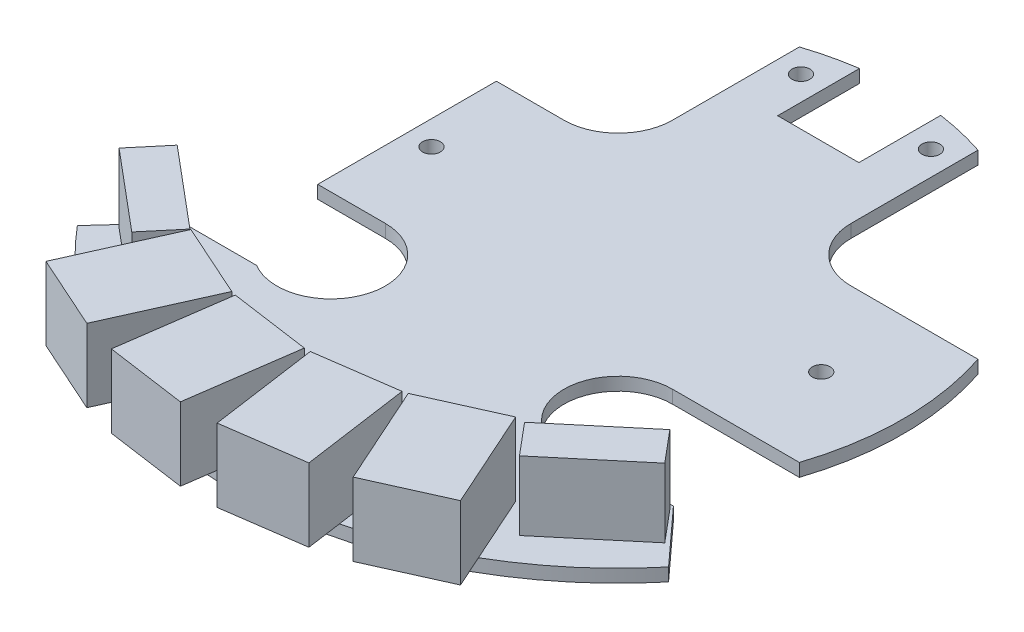
from build123d import *

# Parameters (mm, degrees)
BOSS_EXTRUDE1_DEPTH = 1.6
BOSS_EXTRUDE2_DEPTH = 8.5
BOSS_EXTRUDE3_DEPTH = 9
SKETCH4_R           = 1.1
CUT_EXTRUDE1_DEPTH  = 2.6


with BuildPart() as part:
    # Sketch1 → Boss-Extrude1 (new body)
    with BuildSketch(Plane(origin=(0, 0, 0), x_dir=(1, 0, 0), z_dir=(0, 1, 0))):
        with BuildLine():
            Line((-10.999776277, 17.68), (-10.999776277, 33.3))
            ThreePointArc((-10.999776277, 33.3), (-8.030956433, 34.137791623), (-5, 34.711454567))
            Line((-5, 34.711454567), (-5, 24.633454567))
            Line((-5, 24.633454567), (5, 24.633454567))
            Line((5, 24.633454567), (5, 34.711454567))
            ThreePointArc((5, 34.711454567), (8.031185785, 34.137737667), (11.000223723, 33.299852195))
            Line((11.000223723, 33.299852195), (11.000223723, 17.68))
            ThreePointArc((11.000223723, 17.68), (12.956750425, 12.956526702), (17.680223723, 11))
            Line((17.680223723, 11), (33.300223723, 11))
            ThreePointArc((33.300223723, 11), (35.07, 0), (33.300223723, -11))
            Line((33.300223723, -11), (17.680223723, -11))
            ThreePointArc((17.680223723, -11), (11.24298933, -19.464492467), (21.119504048, -23.406582825))
            Line((21.119504048, -23.406582825), (30.202056601, -23.406582825))
            Line((30.202056601, -23.406582825), (36.4, -30.200102798))
            ThreePointArc((36.4, -30.200102798), (0, -47.297), (-36.4, -30.200102798))
            Line((-36.4, -30.200102798), (-30.202056601, -23.406582825))
            Line((-30.202056601, -23.406582825), (-21.119056601, -23.406582825))
            ThreePointArc((-21.119056601, -23.406582825), (-11.242541883, -19.464492467), (-17.679776277, -11))
            Line((-17.679776277, -11), (-25.999776277, -11))
            Line((-25.999776277, -11), (-25.999776277, 11))
            Line((-25.999776277, 11), (-17.679776277, 11))
            ThreePointArc((-17.679776277, 11), (-12.956302978, 12.956526702), (-10.999776277, 17.68))
        make_face()
    extrude(amount=BOSS_EXTRUDE1_DEPTH)

    # Sketch2 → Boss-Extrude2 (add)
    with BuildSketch(Plane(origin=(0, 1.6, 0), x_dir=(1, 0, 0), z_dir=(0, 1, 0))):
        Polygon((-33.597062742, -27.864051564), (-23.868298315, -36.027454207), (-20.602937258, -32.135948436), (-30.331701685, -23.972545793), align=None)
        Polygon((23.868298315, -36.027454207), (33.597062742, -27.864051564), (30.331701685, -23.972545793), (20.602937258, -32.135948436), align=None)
    extrude(amount=BOSS_EXTRUDE2_DEPTH)

    # Sketch3 → Boss-Extrude3 (add)
    with BuildSketch(Plane(origin=(0, 1.6, 0), x_dir=(1, 0, 0), z_dir=(0, 1, 0))):
        Polygon((-25.517948101, -44.939697826), (-19.990220336, -32.623276846), (-10.866945536, -36.717890005), (-16.394673301, -49.034310985), align=None)
        Polygon((-0.36916096, -38.28278004), (-2.261296496, -51.649523215), (-12.162587737, -50.247941336), (-10.2704522, -36.881198161), align=None)
        Polygon((2.261296496, -51.649523215), (0.36916096, -38.28278004), (10.2704522, -36.881198161), (12.162587737, -50.247941336), align=None)
        Polygon((16.394673301, -49.034310985), (10.866945536, -36.717890005), (19.990220336, -32.623276846), (25.517948101, -44.939697826), align=None)
    extrude(amount=BOSS_EXTRUDE3_DEPTH)

    # Sketch4 → Cut-Extrude1 (cut, through all)
    with BuildSketch(Plane(origin=(0, 1.6, 0), x_dir=(1, 0, 0), z_dir=(0, 1, 0))):
        with Locations((0, -34.8)):
            Circle(SKETCH4_R)
        with Locations((25, 0)):
            Circle(SKETCH4_R)
        with Locations((-23, 0)):
            Circle(SKETCH4_R)
        with Locations((-8, 30.5)):
            Circle(SKETCH4_R)
        with Locations((8, 30.5)):
            Circle(SKETCH4_R)
    extrude(amount=-CUT_EXTRUDE1_DEPTH, mode=Mode.SUBTRACT)


solid = part.part
